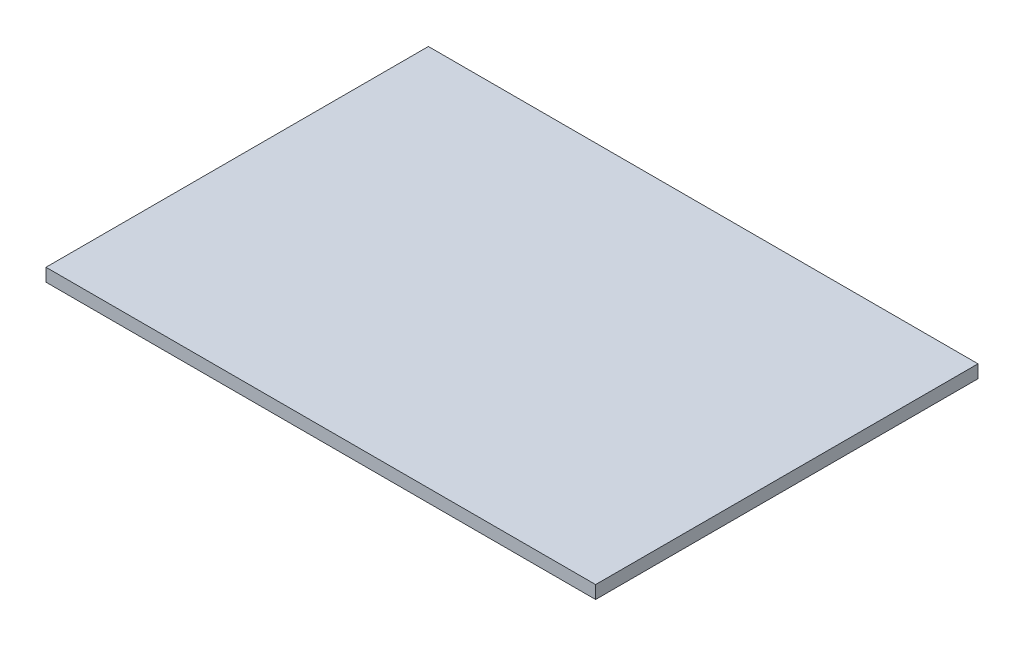
from build123d import *

# Parameters (mm, degrees)
SKETCH1_W           = 424
SKETCH1_H           = 295
BOSS_EXTRUDE1_DEPTH = 10


with BuildPart() as part:
    # Sketch1 → Boss-Extrude1 (new body)
    with BuildSketch(Plane(origin=(0, 0, 0), x_dir=(1, 0, 0), z_dir=(0, 1, 0))):
        Rectangle(SKETCH1_W, SKETCH1_H)
    extrude(amount=-BOSS_EXTRUDE1_DEPTH)


solid = part.part
